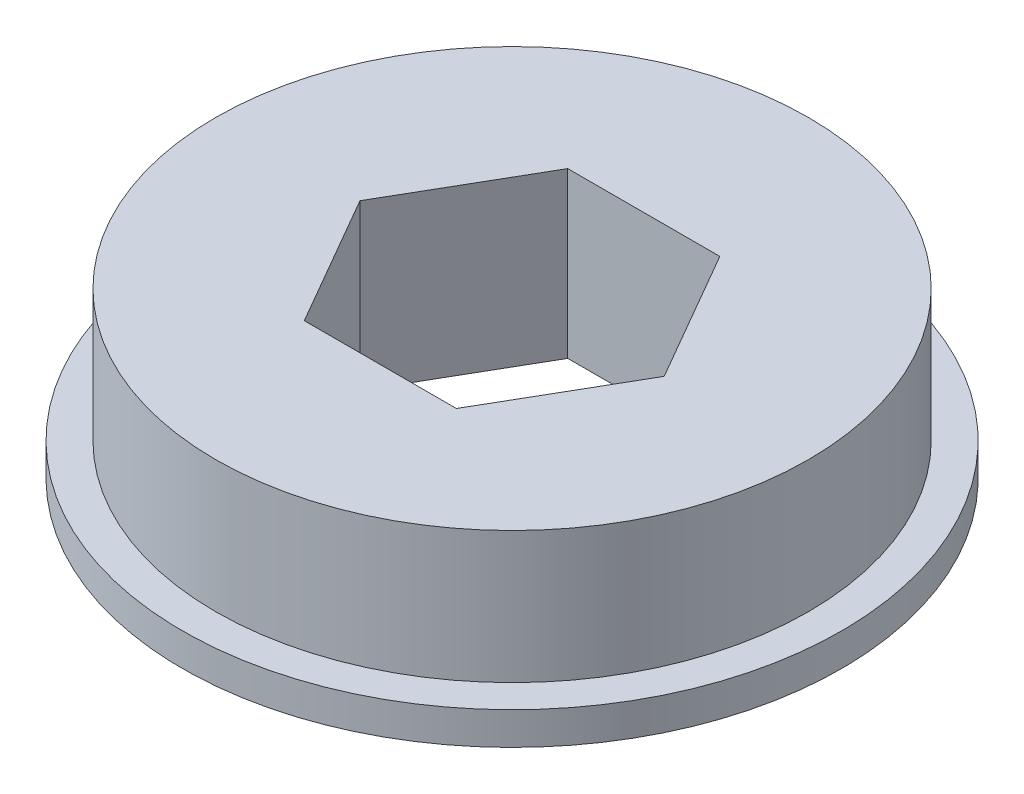
from build123d import *

# Parameters (mm, degrees)
SKETCH1_R           = 14.2875
BOSS_EXTRUDE1_DEPTH = 6.35
SKETCH2_R           = 15.8877
BOSS_EXTRUDE2_DEPTH = 1.5748


with BuildPart() as part:
    # Sketch1 → Boss-Extrude1 (new body)
    with BuildSketch(Plane(origin=(0, 0, 0), x_dir=(1, 0, 0), z_dir=(0, 1, 0))):
        Circle(SKETCH1_R)
        Polygon((7.332348419, 0), (3.666174209, 6.35), (-3.666174209, 6.35), (-7.332348419, 0), (-3.666174209, -6.35), (3.666174209, -6.35), align=None, mode=Mode.SUBTRACT)
    extrude(amount=BOSS_EXTRUDE1_DEPTH)

    # Sketch2 → Boss-Extrude2 (add)
    with BuildSketch(Plane.XZ):
        Circle(SKETCH2_R)
        Polygon((-7.332348419, 0), (-3.666174209, -6.35), (3.666174209, -6.35), (7.332348419, 0), (3.666174209, 6.35), (-3.666174209, 6.35), align=None, mode=Mode.SUBTRACT)
    extrude(amount=BOSS_EXTRUDE2_DEPTH)


solid = part.part
